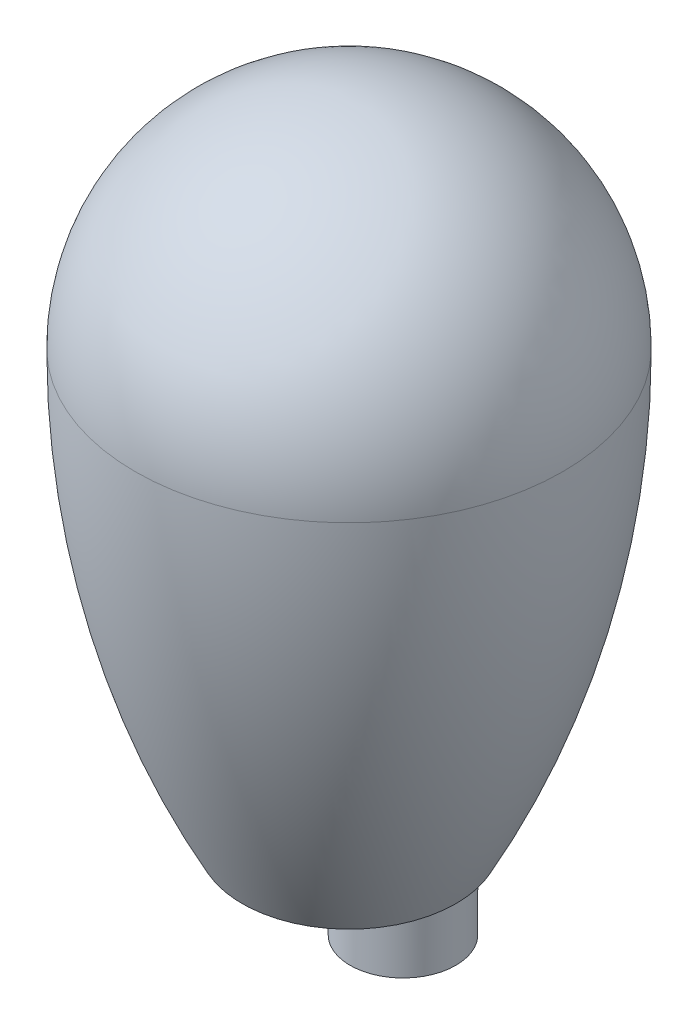
from build123d import *

# Parameters (mm, degrees)
SKETCH2_R           = 0.2475
BOSS_EXTRUDE1_DEPTH = 0.25


with BuildPart() as part:
    # Sketch1 → Revolve2 (revolve)
    with BuildSketch(Plane.XY):
        with BuildLine():
            Line((0, 0), (0, 3))
            ThreePointArc((0, 3), (0.707106781, 2.707106781), (1, 2))
            ThreePointArc((1, 2), (0.873105626, 0.969223594), (0.5, 0))
            Line((0.5, 0), (0, 0))
        make_face()
    revolve(axis=Axis((0, 0, 0), (0, 1, 0)))

    # Sketch2 → Boss-Extrude1 (add)
    with BuildSketch(Plane.XZ):
        with Locations((0.2525, 0)):
            Circle(SKETCH2_R)
        with Locations((-0.2525, 0)):
            Circle(SKETCH2_R)
    extrude(amount=BOSS_EXTRUDE1_DEPTH)


solid = part.part
